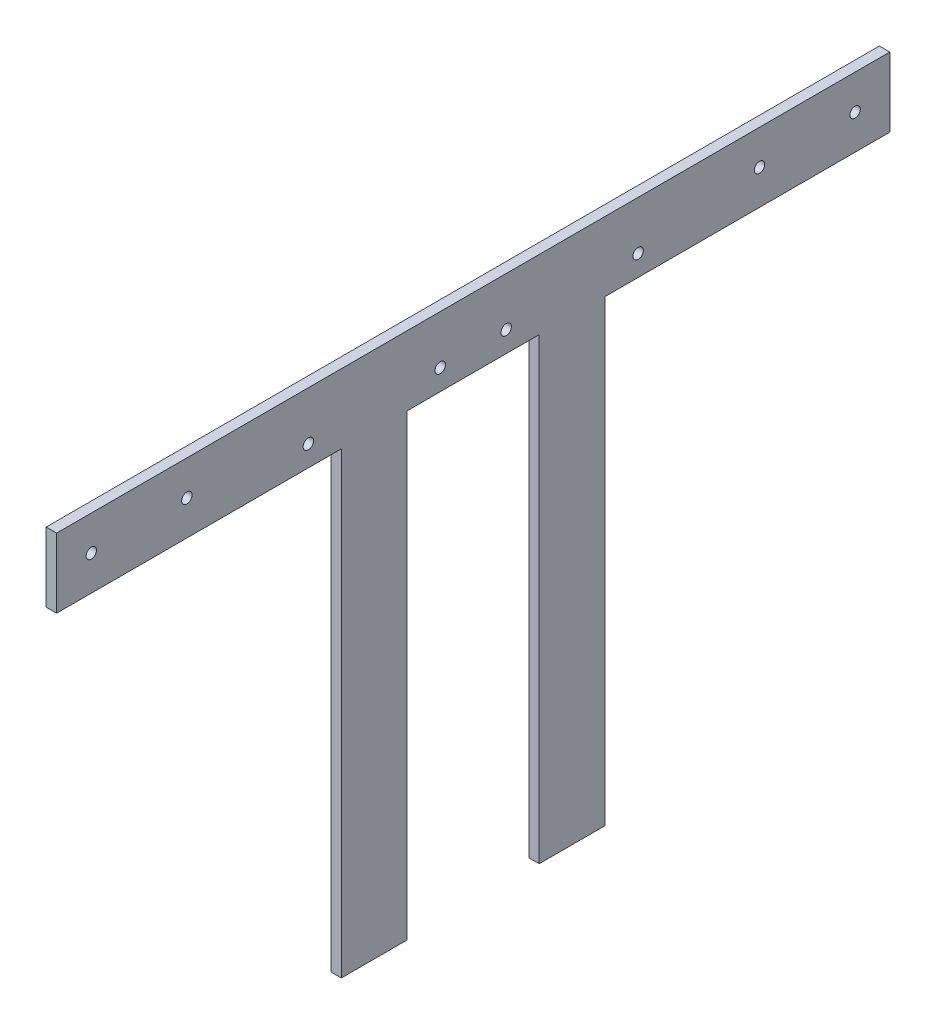
from build123d import *

# Parameters (mm, degrees)
SKETCH_1_R      = 1.5
EXTRUDE_1_DEPTH = 3


with BuildPart() as part:
    # 草图1 → 凸台-拉伸1 (new body)
    with BuildSketch(Plane(origin=(0, 0, 0), x_dir=(0, 0, -1), z_dir=(1, 0, 0))):
        Polygon((0, 0), (240, 0), (240, -20), (158, -20), (158, -152), (139, -152), (139, -20), (101, -20), (101, -152), (82, -152), (82, -20), (0, -20), align=None)
        with Locations((72.5, -14)):
            Circle(SKETCH_1_R, mode=Mode.SUBTRACT)
        with Locations((110.5, -14)):
            Circle(SKETCH_1_R, mode=Mode.SUBTRACT)
        with Locations((129.5, -14)):
            Circle(SKETCH_1_R, mode=Mode.SUBTRACT)
        with Locations((167.5, -14)):
            Circle(SKETCH_1_R, mode=Mode.SUBTRACT)
        with Locations((10, -10)):
            Circle(SKETCH_1_R, mode=Mode.SUBTRACT)
        with Locations((230, -10)):
            Circle(SKETCH_1_R, mode=Mode.SUBTRACT)
        with Locations((37.52, -10)):
            Circle(SKETCH_1_R, mode=Mode.SUBTRACT)
        with Locations((202.48, -10)):
            Circle(SKETCH_1_R, mode=Mode.SUBTRACT)
    extrude(amount=EXTRUDE_1_DEPTH)


solid = part.part
